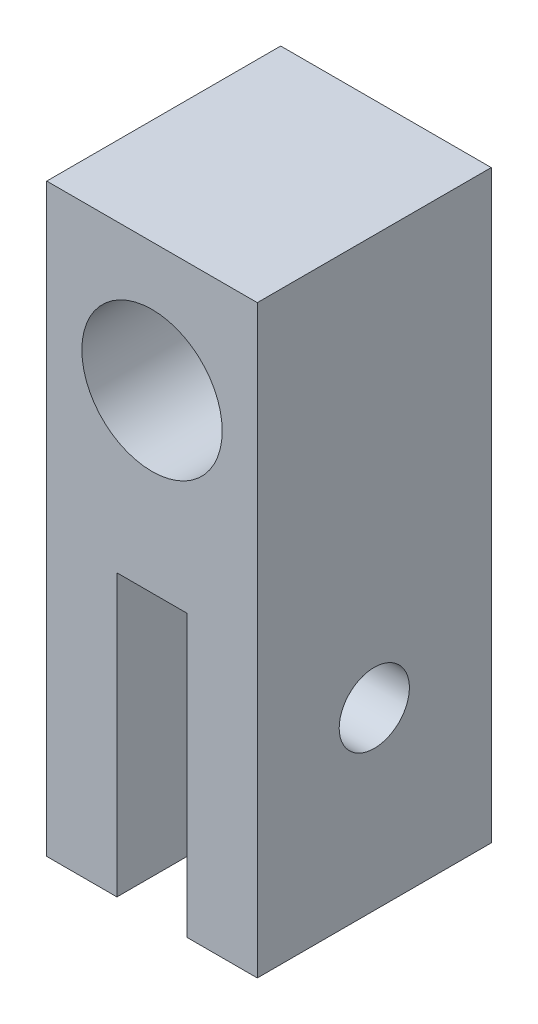
from build123d import *

# Parameters (mm, degrees)
BOSS_EXTRUDE1_DEPTH     = 10
SKETCH3_R               = 1.5
CUT_EXTRUDE1_DEPTH      = 1
CUT_EXTRUDE1_DEPTH_BACK = 10


with BuildPart() as part:
    # Sketch1 → Boss-Extrude1 (new body)
    with BuildSketch(Plane.XY):
        Polygon((-1.5, -0.5), (0, -0.5), (1.5, -0.5), (1.5, -12.5), (4.5, -12.5), (4.5, 12.5), (-4.5, 12.5), (-4.5, -12.5), (-1.5, -12.5), align=None)
        with BuildLine():
            ThreePointArc((3, 7), (2.121320344, 4.878679656), (0, 4))
            ThreePointArc((0, 4), (-2.121320344, 9.121320344), (3, 7))
        make_face(mode=Mode.SUBTRACT)
    extrude(amount=BOSS_EXTRUDE1_DEPTH)

    # Sketch3 → Cut-Extrude1 (cut, two sides)
    with BuildSketch(Plane(origin=(4.5, 0, 0), x_dir=(0, 0, -1), z_dir=(1, 0, 0))) as cut_extrude1_sk:
        with Locations((-5, -5)):
            Circle(SKETCH3_R)
    extrude(amount=CUT_EXTRUDE1_DEPTH, mode=Mode.SUBTRACT)
    extrude(cut_extrude1_sk.sketch, amount=-CUT_EXTRUDE1_DEPTH_BACK, mode=Mode.SUBTRACT)


solid = part.part
